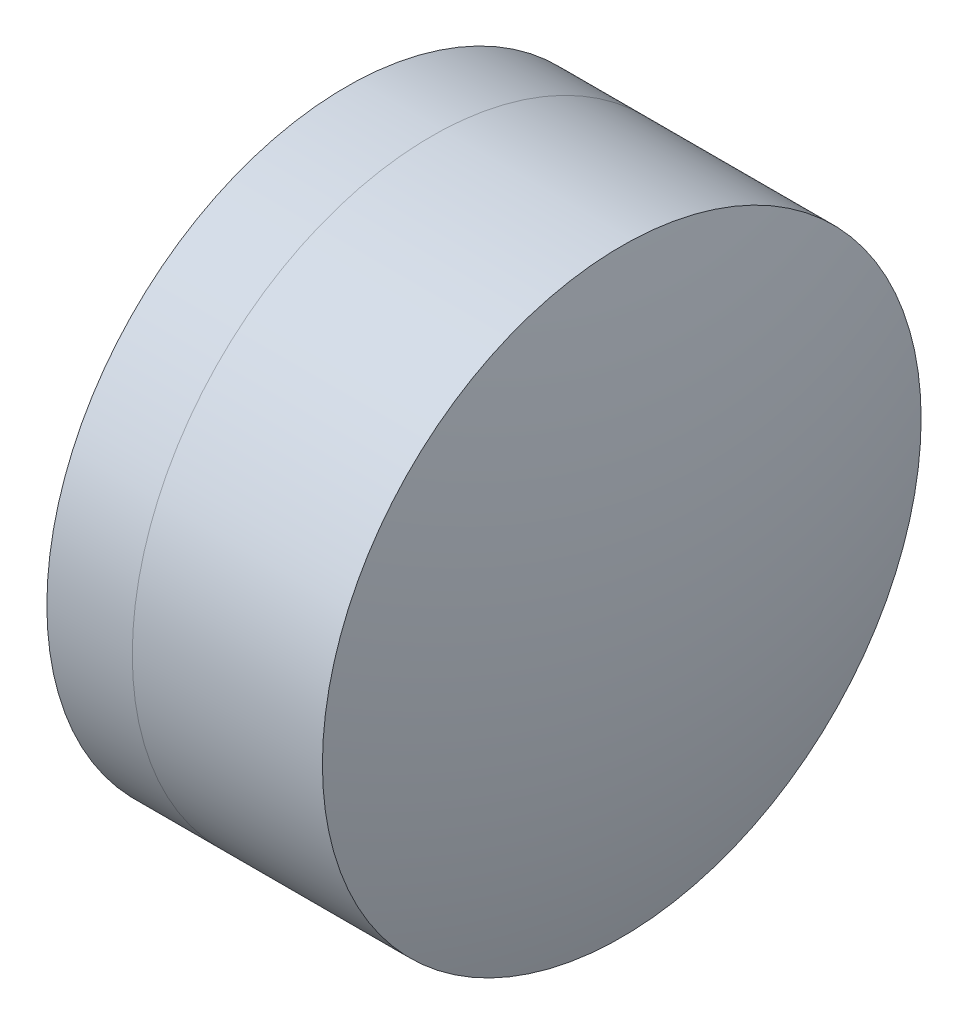
from build123d import *


with BuildPart() as part:
    # 草图1 one side → 旋转1 (revolve)
    with BuildSketch(Plane(origin=(0, 0, 0), x_dir=(1, 0, 0), z_dir=(0, 1, 0)), mode=Mode.PRIVATE) as revolve_1_sk:
        with BuildLine():
            ThreePointArc((1.47109638, 3.175), (1.303812421, 1.591415649), (1.247959484, 0))
            Line((1.247959484, 0), (3.547959484, 0))
            ThreePointArc((3.547959484, 0), (3.245897361, 1.692018333), (2.377028588, 3.175))
            Line((2.377028588, 3.175), (1.47109638, 3.175))
        make_face()
    revolve(revolve_1_sk.sketch.rotate(Axis((-0.816062176, 0, 0), (1, 0, 0)), 180), axis=Axis((-0.816062176, 0, 0), (1, 0, 0)))  # turned: the seam where the file's is


with BuildPart() as body_2:
    # 草图2 one side → 旋转2 (revolve)
    with BuildSketch(Plane(origin=(0, 0, 0), x_dir=(1, 0, 0), z_dir=(0, 1, 0)), mode=Mode.PRIVATE) as revolve_2_sk:
        with BuildLine():
            Line((4.393583028, 3.175), (2.377028588, 3.175))
            ThreePointArc((2.377028588, 3.175), (3.245897361, 1.692018333), (3.547959484, 0))
            Line((3.547959484, 0), (4.847959484, 0))
            ThreePointArc((4.847959484, 0), (4.73378963, 1.603674138), (4.393583028, 3.175))
        make_face()
    revolve(revolve_2_sk.sketch.rotate(Axis((-0.551919993, 0, 0), (1, 0, 0)), 180), axis=Axis((-0.551919993, 0, 0), (1, 0, 0)))  # turned: the seam where the file's is


solid = Compound([part.part, body_2.part])
